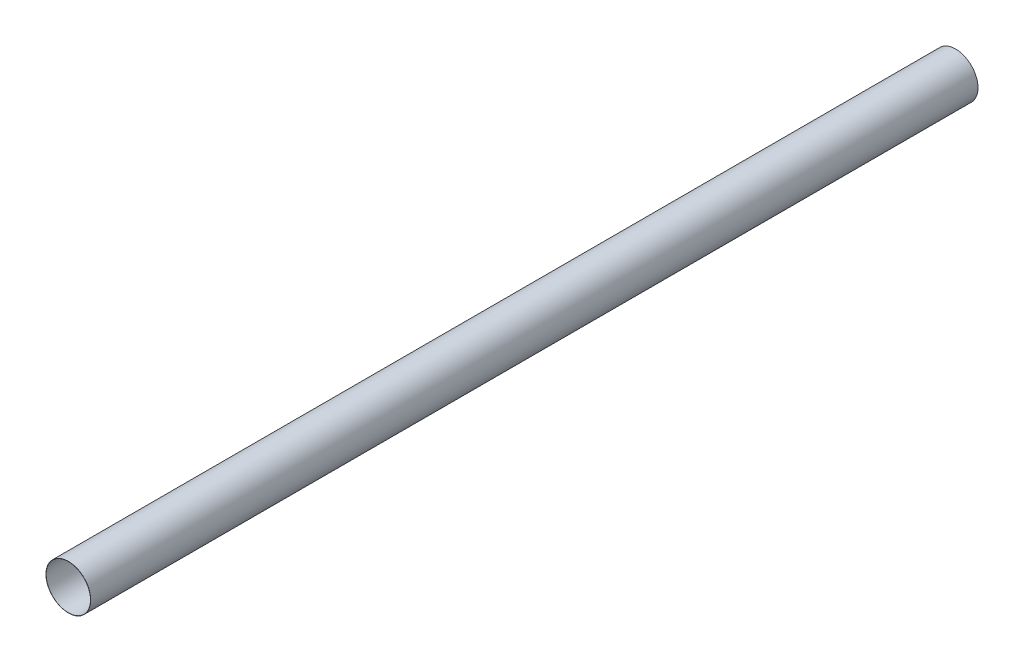
from build123d import *

# Parameters (mm, degrees)
SKETCH1_R           = 252
SKETCH1_R_2         = 250
BOSS_EXTRUDE1_DEPTH = 10000


with BuildPart() as part:
    # Sketch1 → Boss-Extrude1 (new body)
    with BuildSketch(Plane.XY):
        Circle(SKETCH1_R)
        Circle(SKETCH1_R_2, mode=Mode.SUBTRACT)
    extrude(amount=BOSS_EXTRUDE1_DEPTH)


solid = part.part
